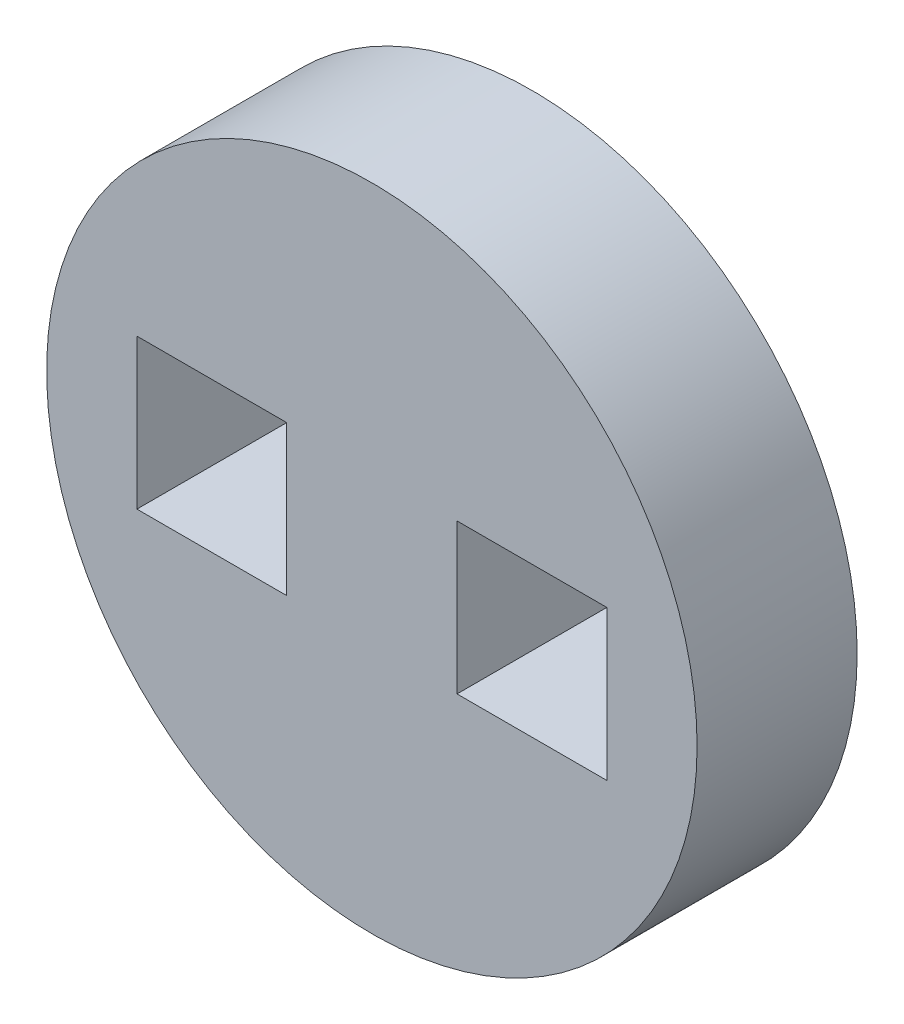
from build123d import *

# Parameters (mm, degrees)
SKETCH1_R           = 6.4516
SKETCH1_W           = 2.9718
SKETCH1_H           = 2.9718
BOSS_EXTRUDE1_DEPTH = 3.175


with BuildPart() as part:
    # Sketch1 → Boss-Extrude1 (new body)
    with BuildSketch(Plane.XY):
        Circle(SKETCH1_R)
        with Locations((-3.175, 0)):
            Rectangle(SKETCH1_W, SKETCH1_H, mode=Mode.SUBTRACT)
        with Locations((3.175, 0)):
            Rectangle(SKETCH1_W, SKETCH1_H, mode=Mode.SUBTRACT)
    extrude(amount=BOSS_EXTRUDE1_DEPTH)


solid = part.part
